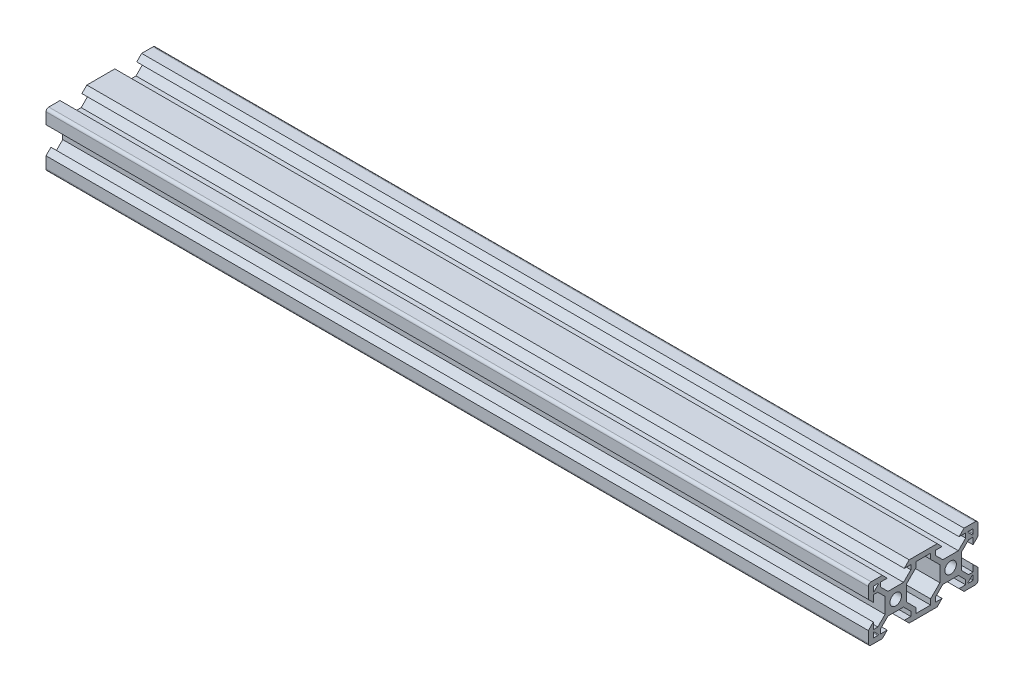
from build123d import *

# Parameters (mm, degrees)
SKETCH5_R           = 2.1
BOSS_EXTRUDE1_DEPTH = 150


with BuildPart() as part:
    # Sketch5 → Boss-Extrude1 (new body, symmetric)
    with BuildSketch(Plane(origin=(0, 0, 0), x_dir=(0, 0, -1), z_dir=(1, 0, 0))):
        with BuildLine():
            Line((-19.998019485, 4.9), (-18.198019485, 3.1))
            Line((-18.198019485, 3.1), (-18.198019485, 5.499339828))
            Line((-18.198019485, 5.499339828), (-16.558019485, 5.499339828))
            Line((-16.558019485, 5.499339828), (-13.9, 2.841320344))
            Line((-13.9, 2.841320344), (-13.9, -2.838679656))
            Line((-13.9, -2.838679656), (-16.558019485, -5.496699141))
            Line((-16.558019485, -5.496699141), (-18.198019485, -5.496699141))
            Line((-18.198019485, -5.496699141), (-18.198019485, -3.1))
            Line((-18.198019485, -3.1), (-19.998019485, -4.9))
            Line((-19.998019485, -4.9), (-19.998019485, -9))
            ThreePointArc((-19.998019485, -9), (-19.705126266, -9.707106781), (-18.998019485, -10))
            Line((-18.998019485, -10), (-14.9, -10))
            Line((-14.9, -10), (-13.1, -8.2))
            Line((-13.1, -8.2), (-15.5, -8.2))
            Line((-15.5, -8.2), (-15.5, -6.56))
            Line((-15.5, -6.56), (-12.84, -3.9))
            Line((-12.84, -3.9), (-7.16, -3.9))
            Line((-7.16, -3.9), (-4.5, -6.56))
            Line((-4.5, -6.56), (-4.5, -8.2))
            Line((-4.5, -8.2), (-6.9, -8.2))
            Line((-6.9, -8.2), (-5.1, -10))
            Line((-5.1, -10), (5.1, -10))
            Line((5.1, -10), (6.9, -8.2))
            Line((6.9, -8.2), (4.496038969, -8.2))
            Line((4.496038969, -8.2), (4.496038969, -6.56))
            Line((4.496038969, -6.56), (7.156038969, -3.9))
            Line((7.156038969, -3.9), (12.836038969, -3.9))
            Line((12.836038969, -3.9), (15.496038969, -6.56))
            Line((15.496038969, -6.56), (15.496038969, -8.2))
            Line((15.496038969, -8.2), (13.1, -8.2))
            Line((13.1, -8.2), (14.9, -10))
            Line((14.9, -10), (19.001980515, -10))
            ThreePointArc((19.001980515, -10), (19.709087297, -9.707106781), (20.001980515, -9))
            Line((20.001980515, -9), (20.001980515, -4.9))
            Line((20.001980515, -4.9), (18.201980515, -3.1))
            Line((18.201980515, -3.1), (18.201980515, -5.504621202))
            Line((18.201980515, -5.504621202), (16.561980515, -5.504621202))
            Line((16.561980515, -5.504621202), (13.9, -2.842640687))
            Line((13.9, -2.842640687), (13.9, 2.837359313))
            Line((13.9, 2.837359313), (16.561980515, 5.499339828))
            Line((16.561980515, 5.499339828), (18.201980515, 5.499339828))
            Line((18.201980515, 5.499339828), (18.201980515, 3.1))
            Line((18.201980515, 3.1), (20.001980515, 4.9))
            Line((20.001980515, 4.9), (20.001980515, 9))
            ThreePointArc((20.001980515, 9), (19.709087297, 9.707106781), (19.001980515, 10))
            Line((19.001980515, 10), (14.9, 10))
            Line((14.9, 10), (13.1, 8.2))
            Line((13.1, 8.2), (15.501320344, 8.2))
            Line((15.501320344, 8.2), (15.501320344, 6.56))
            Line((15.501320344, 6.56), (12.841320344, 3.9))
            Line((12.841320344, 3.9), (7.161320344, 3.9))
            Line((7.161320344, 3.9), (4.501320344, 6.56))
            Line((4.501320344, 6.56), (4.501320344, 8.2))
            Line((4.501320344, 8.2), (6.9, 8.2))
            Line((6.9, 8.2), (5.1, 10))
            Line((5.1, 10), (-5.1, 10))
            Line((-5.1, 10), (-6.9, 8.2))
            Line((-6.9, 8.2), (-4.501320344, 8.2))
            Line((-4.501320344, 8.2), (-4.501320344, 6.56))
            Line((-4.501320344, 6.56), (-7.161320344, 3.9))
            Line((-7.161320344, 3.9), (-12.841320344, 3.9))
            Line((-12.841320344, 3.9), (-15.501320344, 6.56))
            Line((-15.501320344, 6.56), (-15.501320344, 8.2))
            Line((-15.501320344, 8.2), (-13.1, 8.2))
            Line((-13.1, 8.2), (-14.9, 10))
            Line((-14.9, 10), (-18.998019485, 10))
            ThreePointArc((-18.998019485, 10), (-19.705126266, 9.707106781), (-19.998019485, 9))
            Line((-19.998019485, 9), (-19.998019485, 4.9))
        make_face()
        with Locations((-10, 0)):
            Circle(SKETCH5_R, mode=Mode.SUBTRACT)
        with Locations((10, 0)):
            Circle(SKETCH5_R, mode=Mode.SUBTRACT)
        Polygon((6.1, -2.84), (6.1, 2.84), (2.7, 6.24), (2.7, 8.2), (-2.7, 8.2), (-2.7, 6.24), (-6.1, 2.84), (-6.1, -2.84), (-2.7, -6.24), (-2.7, -8.2), (2.7, -8.2), (2.7, -6.24), align=None, mode=Mode.SUBTRACT)
        with BuildLine():
            Line((16.571320344, 8.2), (18.001980515, 8.2))
            ThreePointArc((18.001980515, 8.2), (18.143401872, 8.141421356), (18.201980515, 8))
            Line((18.201980515, 8), (18.201980515, 6.569339828))
            ThreePointArc((18.201980515, 6.569339828), (18.078517202, 6.384563922), (17.860559159, 6.427918472))
            Line((17.860559159, 6.427918472), (16.429898987, 7.858578644))
            ThreePointArc((16.429898987, 7.858578644), (16.386544437, 8.076536686), (16.571320344, 8.2))
        make_face(mode=Mode.SUBTRACT)
        with BuildLine():
            Line((16.571320344, -8.2), (18.001980515, -8.2))
            ThreePointArc((18.001980515, -8.2), (18.143401872, -8.141421356), (18.201980515, -8))
            Line((18.201980515, -8), (18.201980515, -6.569339828))
            ThreePointArc((18.201980515, -6.569339828), (18.078517202, -6.384563922), (17.860559159, -6.427918472))
            Line((17.860559159, -6.427918472), (16.429898987, -7.858578644))
            ThreePointArc((16.429898987, -7.858578644), (16.386544437, -8.076536686), (16.571320344, -8.2))
        make_face(mode=Mode.SUBTRACT)
        with BuildLine():
            Line((-17.860559159, 6.427918472), (-16.429898987, 7.858578644))
            ThreePointArc((-16.429898987, 7.858578644), (-16.386544437, 8.076536686), (-16.571320344, 8.2))
            Line((-16.571320344, 8.2), (-18.001980515, 8.2))
            ThreePointArc((-18.001980515, 8.2), (-18.143401872, 8.141421356), (-18.201980515, 8))
            Line((-18.201980515, 8), (-18.201980515, 6.569339828))
            ThreePointArc((-18.201980515, 6.569339828), (-18.078517202, 6.384563922), (-17.860559159, 6.427918472))
        make_face(mode=Mode.SUBTRACT)
        with BuildLine():
            Line((-16.571320344, -8.2), (-18.001980515, -8.2))
            ThreePointArc((-18.001980515, -8.2), (-18.143401872, -8.141421356), (-18.201980515, -8))
            Line((-18.201980515, -8), (-18.201980515, -6.569339828))
            ThreePointArc((-18.201980515, -6.569339828), (-18.078517202, -6.384563922), (-17.860559159, -6.427918472))
            Line((-17.860559159, -6.427918472), (-16.429898987, -7.858578644))
            ThreePointArc((-16.429898987, -7.858578644), (-16.386544437, -8.076536686), (-16.571320344, -8.2))
        make_face(mode=Mode.SUBTRACT)
    extrude(amount=BOSS_EXTRUDE1_DEPTH, both=True)


solid = part.part
